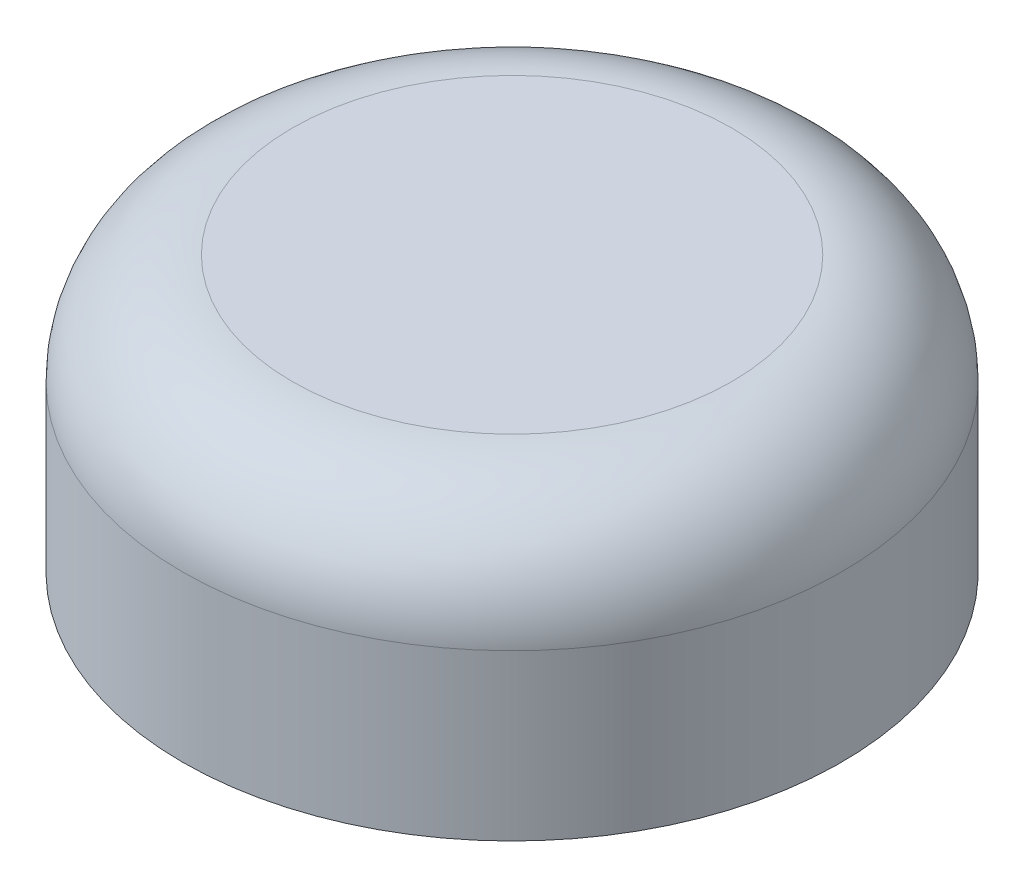
from build123d import *

# Parameters (mm, degrees)
SKETCH1_R           = 6
SKETCH1_R_2         = 5
BOSS_EXTRUDE1_DEPTH = 3
SKETCH2_R           = 6
BOSS_EXTRUDE2_DEPTH = 2
FILLET1_R           = 2


with BuildPart() as part:
    # Sketch1 → Boss-Extrude1 (new body)
    with BuildSketch(Plane(origin=(0, 0, 0), x_dir=(1, 0, 0), z_dir=(0, 1, 0))):
        with Locations((-0.477560777, 0)):
            Circle(SKETCH1_R)
        with Locations((-0.477560777, 0)):
            Circle(SKETCH1_R_2, mode=Mode.SUBTRACT)
    extrude(amount=BOSS_EXTRUDE1_DEPTH)

    # Sketch2 → Boss-Extrude2 (add)
    with BuildSketch(Plane(origin=(0, 3, 0), x_dir=(1, 0, 0), z_dir=(0, 1, 0))):
        with Locations((-0.477560777, 0)):
            Circle(SKETCH2_R)
    extrude(amount=BOSS_EXTRUDE2_DEPTH)

    # Fillet1
    fillet1_edges = [part.edges().sort_by_distance(p)[0] for p in [
        (-6.477560777, 5, 0),
    ]]
    fillet(fillet1_edges, radius=FILLET1_R)


solid = part.part
